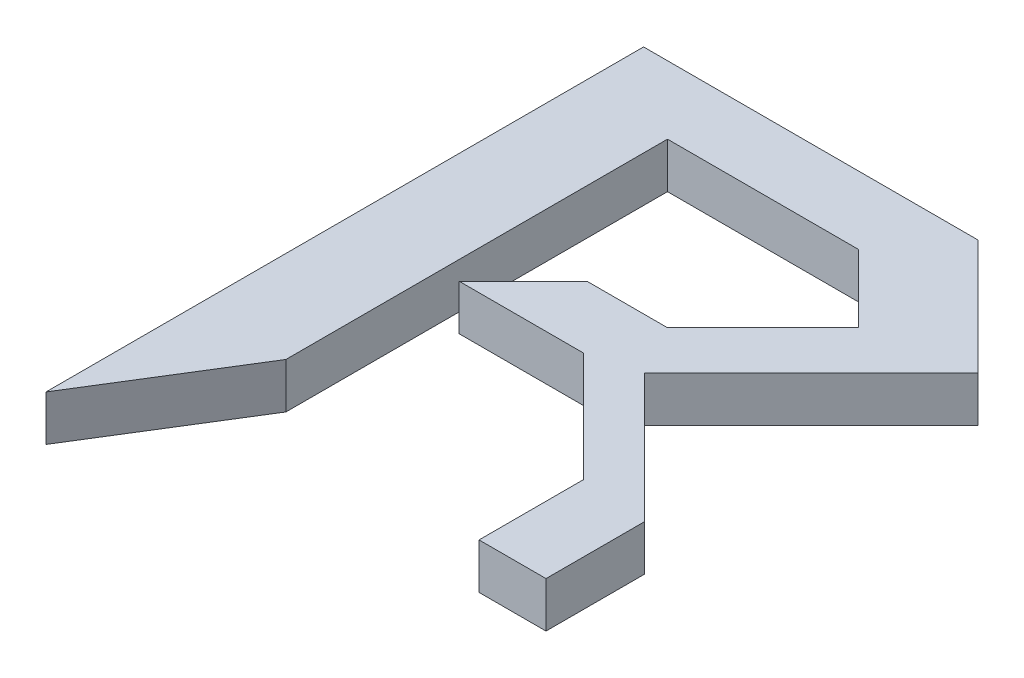
from build123d import *

# Parameters (mm, degrees)
BOSS_EXTRUDE1_DEPTH = 5


with BuildPart() as part:
    # Sketch1 → Boss-Extrude1 (new body)
    with BuildSketch(Plane(origin=(0, 0, 0), x_dir=(1, 0, 0), z_dir=(0, 1, 0))):
        Polygon((-339.799413006, 126.304683991), (-339.799413006, 191.992892094), (-303.040106148, 191.992892094), (-290.400599698, 179.353385644), (-308.734522065, 161.019463277), (-294.552751732, 146.837692944), (-294.552751732, 136.018956443), (-301.910980799, 136.018956443), (-301.910980799, 147.500427473), (-313.95979318, 159.549239854), (-327.618746258, 159.549239854), (-320.592033082, 166.575953029), (-311.753745416, 166.575953029), (-301.268571849, 177.061126596), (-308.734454598, 184.527009345), (-329.704801732, 184.527009345), (-329.704801732, 142.586315078), align=None)
    extrude(amount=BOSS_EXTRUDE1_DEPTH)


solid = part.part
